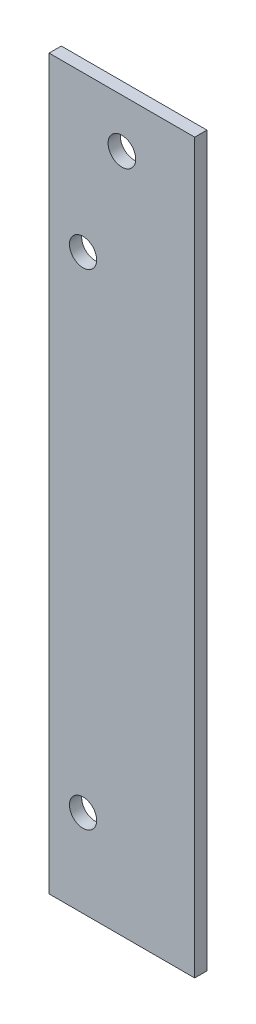
from build123d import *

# Parameters (mm, degrees)
SKETCH1_W          = 19.05
SKETCH1_H          = 95.25
EXTRUDE1_DEPTH     = 1.6002
SKETCH2_R          = 1.8034
CUT_EXTRUDE1_DEPTH = 1.6002
SKETCH3_R          = 1.778
CUT_EXTRUDE2_DEPTH = 2.54


with BuildPart() as part:
    # Sketch1 → Extrude1 (new body)
    with BuildSketch(Plane.XY):
        with Locations((9.525, -47.625)):
            Rectangle(SKETCH1_W, SKETCH1_H)
    extrude(amount=EXTRUDE1_DEPTH)

    # Sketch2 → Cut-Extrude1 (cut)
    with BuildSketch(Plane.XY.offset(1.6002)):
        with Locations((9.525, -6.35)):
            Circle(SKETCH2_R)
    extrude(amount=-CUT_EXTRUDE1_DEPTH, mode=Mode.SUBTRACT)

    # Sketch3 → Cut-Extrude2 (cut)
    with BuildSketch(Plane.XY.offset(1.6002)):
        with Locations((4.445, -20.32)):
            Circle(SKETCH3_R)
        with Locations((4.445, -83.82)):
            Circle(SKETCH3_R)
    extrude(amount=-CUT_EXTRUDE2_DEPTH, mode=Mode.SUBTRACT)


solid = part.part
